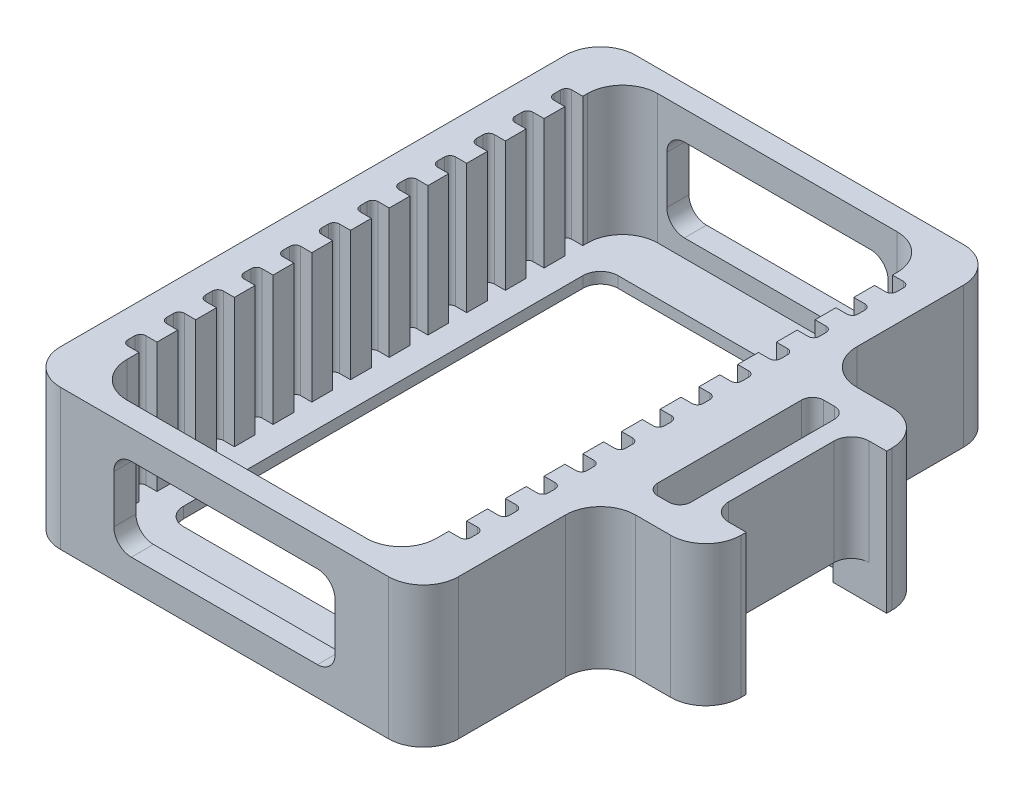
from build123d import *

# Parameters (mm, degrees)
SKETCH2_W                 = 36
SKETCH2_H                 = 52
BOSS_EXTRUDE3_DEPTH       = 12.7
SHELL2_T                  = -1
SHELL2_THICKNESS_2_FACE_W = 34
SHELL2_THICKNESS_2_FACE_H = 11.7
SHELL2_THICKNESS_2_DEPTH  = 1
SHELL2_THICKNESS_3_FACE_W = 34
SHELL2_THICKNESS_3_FACE_H = 11.7
SHELL2_THICKNESS_3_DEPTH  = 1
SHELL2_THICKNESS_4_FACE_W = 48
SHELL2_THICKNESS_4_FACE_H = 11.7
SHELL2_THICKNESS_4_DEPTH  = 3
SHELL2_THICKNESS_5_FACE_W = 48
SHELL2_THICKNESS_5_FACE_H = 11.7
SHELL2_THICKNESS_5_DEPTH  = 3
CUT_EXTRUDE1_DEPTH        = 11.7
LPATTERN1_COUNT           = 12
LPATTERN1_PITCH           = 3.5
LPATTERN1_COPY_1_DEPTH    = 11.7
LPATTERN1_COPY_2_DEPTH    = 11.7
LPATTERN1_COPY_3_DEPTH    = 11.7
LPATTERN1_COPY_4_DEPTH    = 11.7
LPATTERN1_COPY_5_DEPTH    = 11.7
LPATTERN1_COPY_6_DEPTH    = 11.7
LPATTERN1_COPY_7_DEPTH    = 11.7
LPATTERN1_COPY_8_DEPTH    = 11.7
LPATTERN1_COPY_9_DEPTH    = 11.7
LPATTERN1_COPY_10_DEPTH   = 11.7
LPATTERN1_COPY_11_DEPTH   = 11.7
CUT_EXTRUDE3_DEPTH        = 57.473799235
FILLET5_R                 = 3.175
SKETCH9_W                 = 9.525
SKETCH9_H                 = 20
BOSS_EXTRUDE6_DEPTH       = 12.7
CUT_EXTRUDE5_DEPTH        = 40.936394742
SKETCH11_W                = 3.175
SKETCH11_H                = 12.7
CUT_EXTRUDE6_DEPTH        = 40.936394742
FILLET6_R                 = 3.175
CUT_EXTRUDE7_REACH        = 53.291
SKETCH12_W                = 12.7
SKETCH12_H                = 3.175
FILLET8_R                 = 1.5875
SKETCH7_W                 = 23.3
SKETCH7_H                 = 39.3
CUT_EXTRUDE8_DEPTH        = 12.7
FILLET9_R                 = 1.5875


with BuildPart() as part:
    # Sketch2 → Boss-Extrude3 (new body)
    with BuildSketch(Plane(origin=(0, 0, 0), x_dir=(1, 0, 0), z_dir=(0, 1, 0))):
        Rectangle(SKETCH2_W, SKETCH2_H)
    extrude(amount=BOSS_EXTRUDE3_DEPTH)

    # Shell2
    shell2_openings = [part.faces().sort_by_distance(p)[0] for p in [
        (0, 12.7, 0),
    ]]
    offset(amount=SHELL2_T, openings=shell2_openings, kind=Kind.INTERSECTION)

    # Shell2 thickness 2 face (on inner face of the shell) → Shell2 thickness 2 (add)
    with BuildSketch(Plane(origin=(0, 6.85, -25), x_dir=(-1, 0, 0), z_dir=(0, 0, -1))):
        Rectangle(SHELL2_THICKNESS_2_FACE_W, SHELL2_THICKNESS_2_FACE_H)
    extrude(amount=-SHELL2_THICKNESS_2_DEPTH)

    # Shell2 thickness 3 face (on inner face of the shell) → Shell2 thickness 3 (add)
    with BuildSketch(Plane(origin=(0, 6.85, 25), x_dir=(1, 0, 0), z_dir=(0, 0, 1))):
        Rectangle(SHELL2_THICKNESS_3_FACE_W, SHELL2_THICKNESS_3_FACE_H)
    extrude(amount=-SHELL2_THICKNESS_3_DEPTH)

    # Shell2 thickness 4 face (on inner face of the shell) → Shell2 thickness 4 (add)
    with BuildSketch(Plane(origin=(-17, 6.85, 0), x_dir=(0, 0, -1), z_dir=(-1, 0, 0))):
        Rectangle(SHELL2_THICKNESS_4_FACE_W, SHELL2_THICKNESS_4_FACE_H)
    extrude(amount=-SHELL2_THICKNESS_4_DEPTH)

    # Shell2 thickness 5 face (on inner face of the shell) → Shell2 thickness 5 (add)
    with BuildSketch(Plane(origin=(17, 6.85, 0), x_dir=(0, 0, 1), z_dir=(1, 0, 0))):
        Rectangle(SHELL2_THICKNESS_5_FACE_W, SHELL2_THICKNESS_5_FACE_H)
    extrude(amount=-SHELL2_THICKNESS_5_DEPTH)

    # Sketch5 → Cut-Extrude1 (cut)
    with BuildSketch(Plane(origin=(0, 12.7, 0), x_dir=(1, 0, 0), z_dir=(0, 1, 0))):
        with BuildLine():
            Line((-14, 20.4), (-15, 20.4))
            ThreePointArc((-15, 20.4), (-15.353553391, 20.253553391), (-15.5, 19.9))
            Line((-15.5, 19.9), (-15.5, 19.28))
            ThreePointArc((-15.5, 19.28), (-15.353553391, 18.926446609), (-15, 18.78))
            Line((-15, 18.78), (-14, 18.78))
            Line((-14, 18.78), (-14, 20.4))
        make_face()
    cut_extrude1 = extrude(amount=-CUT_EXTRUDE1_DEPTH, mode=Mode.SUBTRACT)

    # Mirror1: Cut-Extrude1 across plane
    add(cut_extrude1.mirror(Plane(origin=(0, 0, 0), x_dir=(0, 0, 1), z_dir=(1, 0, 0))), mode=Mode.SUBTRACT)

    # LPattern1: Cut-Extrude1 ×12
    with Locations(*[(0, 0, i * LPATTERN1_PITCH) for i in range(1, LPATTERN1_COUNT)]):
        add(cut_extrude1, mode=Mode.SUBTRACT)

    # LPattern1 copy 1 sketch → LPattern1 copy 1 (cut)
    with BuildSketch(Plane(origin=(0, 12.7, 3.5), x_dir=(-1, 0, 0), z_dir=(0, 1, 0))):
        with BuildLine():
            Line((-14, -20.4), (-15, -20.4))
            ThreePointArc((-15, -20.4), (-15.353553391, -20.253553391), (-15.5, -19.9))
            Line((-15.5, -19.9), (-15.5, -19.28))
            ThreePointArc((-15.5, -19.28), (-15.353553391, -18.926446609), (-15, -18.78))
            Line((-15, -18.78), (-14, -18.78))
            Line((-14, -18.78), (-14, -20.4))
        make_face()
    extrude(amount=-LPATTERN1_COPY_1_DEPTH, mode=Mode.SUBTRACT)

    # LPattern1 copy 2 sketch → LPattern1 copy 2 (cut)
    with BuildSketch(Plane(origin=(0, 12.7, 7), x_dir=(-1, 0, 0), z_dir=(0, 1, 0))):
        with BuildLine():
            Line((-14, -20.4), (-15, -20.4))
            ThreePointArc((-15, -20.4), (-15.353553391, -20.253553391), (-15.5, -19.9))
            Line((-15.5, -19.9), (-15.5, -19.28))
            ThreePointArc((-15.5, -19.28), (-15.353553391, -18.926446609), (-15, -18.78))
            Line((-15, -18.78), (-14, -18.78))
            Line((-14, -18.78), (-14, -20.4))
        make_face()
    extrude(amount=-LPATTERN1_COPY_2_DEPTH, mode=Mode.SUBTRACT)

    # LPattern1 copy 3 sketch → LPattern1 copy 3 (cut)
    with BuildSketch(Plane(origin=(0, 12.7, 10.5), x_dir=(-1, 0, 0), z_dir=(0, 1, 0))):
        with BuildLine():
            Line((-14, -20.4), (-15, -20.4))
            ThreePointArc((-15, -20.4), (-15.353553391, -20.253553391), (-15.5, -19.9))
            Line((-15.5, -19.9), (-15.5, -19.28))
            ThreePointArc((-15.5, -19.28), (-15.353553391, -18.926446609), (-15, -18.78))
            Line((-15, -18.78), (-14, -18.78))
            Line((-14, -18.78), (-14, -20.4))
        make_face()
    extrude(amount=-LPATTERN1_COPY_3_DEPTH, mode=Mode.SUBTRACT)

    # LPattern1 copy 4 sketch → LPattern1 copy 4 (cut)
    with BuildSketch(Plane(origin=(0, 12.7, 14), x_dir=(-1, 0, 0), z_dir=(0, 1, 0))):
        with BuildLine():
            Line((-14, -20.4), (-15, -20.4))
            ThreePointArc((-15, -20.4), (-15.353553391, -20.253553391), (-15.5, -19.9))
            Line((-15.5, -19.9), (-15.5, -19.28))
            ThreePointArc((-15.5, -19.28), (-15.353553391, -18.926446609), (-15, -18.78))
            Line((-15, -18.78), (-14, -18.78))
            Line((-14, -18.78), (-14, -20.4))
        make_face()
    extrude(amount=-LPATTERN1_COPY_4_DEPTH, mode=Mode.SUBTRACT)

    # LPattern1 copy 5 sketch → LPattern1 copy 5 (cut)
    with BuildSketch(Plane(origin=(0, 12.7, 17.5), x_dir=(-1, 0, 0), z_dir=(0, 1, 0))):
        with BuildLine():
            Line((-14, -20.4), (-15, -20.4))
            ThreePointArc((-15, -20.4), (-15.353553391, -20.253553391), (-15.5, -19.9))
            Line((-15.5, -19.9), (-15.5, -19.28))
            ThreePointArc((-15.5, -19.28), (-15.353553391, -18.926446609), (-15, -18.78))
            Line((-15, -18.78), (-14, -18.78))
            Line((-14, -18.78), (-14, -20.4))
        make_face()
    extrude(amount=-LPATTERN1_COPY_5_DEPTH, mode=Mode.SUBTRACT)

    # LPattern1 copy 6 sketch → LPattern1 copy 6 (cut)
    with BuildSketch(Plane(origin=(0, 12.7, 21), x_dir=(-1, 0, 0), z_dir=(0, 1, 0))):
        with BuildLine():
            Line((-14, -20.4), (-15, -20.4))
            ThreePointArc((-15, -20.4), (-15.353553391, -20.253553391), (-15.5, -19.9))
            Line((-15.5, -19.9), (-15.5, -19.28))
            ThreePointArc((-15.5, -19.28), (-15.353553391, -18.926446609), (-15, -18.78))
            Line((-15, -18.78), (-14, -18.78))
            Line((-14, -18.78), (-14, -20.4))
        make_face()
    extrude(amount=-LPATTERN1_COPY_6_DEPTH, mode=Mode.SUBTRACT)

    # LPattern1 copy 7 sketch → LPattern1 copy 7 (cut)
    with BuildSketch(Plane(origin=(0, 12.7, 24.5), x_dir=(-1, 0, 0), z_dir=(0, 1, 0))):
        with BuildLine():
            Line((-14, -20.4), (-15, -20.4))
            ThreePointArc((-15, -20.4), (-15.353553391, -20.253553391), (-15.5, -19.9))
            Line((-15.5, -19.9), (-15.5, -19.28))
            ThreePointArc((-15.5, -19.28), (-15.353553391, -18.926446609), (-15, -18.78))
            Line((-15, -18.78), (-14, -18.78))
            Line((-14, -18.78), (-14, -20.4))
        make_face()
    extrude(amount=-LPATTERN1_COPY_7_DEPTH, mode=Mode.SUBTRACT)

    # LPattern1 copy 8 sketch → LPattern1 copy 8 (cut)
    with BuildSketch(Plane(origin=(0, 12.7, 28), x_dir=(-1, 0, 0), z_dir=(0, 1, 0))):
        with BuildLine():
            Line((-14, -20.4), (-15, -20.4))
            ThreePointArc((-15, -20.4), (-15.353553391, -20.253553391), (-15.5, -19.9))
            Line((-15.5, -19.9), (-15.5, -19.28))
            ThreePointArc((-15.5, -19.28), (-15.353553391, -18.926446609), (-15, -18.78))
            Line((-15, -18.78), (-14, -18.78))
            Line((-14, -18.78), (-14, -20.4))
        make_face()
    extrude(amount=-LPATTERN1_COPY_8_DEPTH, mode=Mode.SUBTRACT)

    # LPattern1 copy 9 sketch → LPattern1 copy 9 (cut)
    with BuildSketch(Plane(origin=(0, 12.7, 31.5), x_dir=(-1, 0, 0), z_dir=(0, 1, 0))):
        with BuildLine():
            Line((-14, -20.4), (-15, -20.4))
            ThreePointArc((-15, -20.4), (-15.353553391, -20.253553391), (-15.5, -19.9))
            Line((-15.5, -19.9), (-15.5, -19.28))
            ThreePointArc((-15.5, -19.28), (-15.353553391, -18.926446609), (-15, -18.78))
            Line((-15, -18.78), (-14, -18.78))
            Line((-14, -18.78), (-14, -20.4))
        make_face()
    extrude(amount=-LPATTERN1_COPY_9_DEPTH, mode=Mode.SUBTRACT)

    # LPattern1 copy 10 sketch → LPattern1 copy 10 (cut)
    with BuildSketch(Plane(origin=(0, 12.7, 35), x_dir=(-1, 0, 0), z_dir=(0, 1, 0))):
        with BuildLine():
            Line((-14, -20.4), (-15, -20.4))
            ThreePointArc((-15, -20.4), (-15.353553391, -20.253553391), (-15.5, -19.9))
            Line((-15.5, -19.9), (-15.5, -19.28))
            ThreePointArc((-15.5, -19.28), (-15.353553391, -18.926446609), (-15, -18.78))
            Line((-15, -18.78), (-14, -18.78))
            Line((-14, -18.78), (-14, -20.4))
        make_face()
    extrude(amount=-LPATTERN1_COPY_10_DEPTH, mode=Mode.SUBTRACT)

    # LPattern1 copy 11 sketch → LPattern1 copy 11 (cut)
    with BuildSketch(Plane(origin=(0, 12.7, 38.5), x_dir=(-1, 0, 0), z_dir=(0, 1, 0))):
        with BuildLine():
            Line((-14, -20.4), (-15, -20.4))
            ThreePointArc((-15, -20.4), (-15.353553391, -20.253553391), (-15.5, -19.9))
            Line((-15.5, -19.9), (-15.5, -19.28))
            ThreePointArc((-15.5, -19.28), (-15.353553391, -18.926446609), (-15, -18.78))
            Line((-15, -18.78), (-14, -18.78))
            Line((-14, -18.78), (-14, -20.4))
        make_face()
    extrude(amount=-LPATTERN1_COPY_11_DEPTH, mode=Mode.SUBTRACT)

    # Sketch8 → Cut-Extrude3 (cut, through all)
    with BuildSketch(Plane(origin=(0, 0, -26), x_dir=(-1, 0, 0), z_dir=(0, 0, -1))):
        with BuildLine():
            Line((-8.4125, 10.1), (8.4125, 10.1))
            ThreePointArc((8.4125, 10.1), (9.535032015, 9.635032015), (10, 8.5125))
            Line((10, 8.5125), (10, 4.1875))
            ThreePointArc((10, 4.1875), (9.535032015, 3.064967985), (8.4125, 2.6))
            Line((8.4125, 2.6), (-8.4125, 2.6))
            ThreePointArc((-8.4125, 2.6), (-9.535032015, 3.064967985), (-10, 4.1875))
            Line((-10, 4.1875), (-10, 8.5125))
            ThreePointArc((-10, 8.5125), (-9.535032015, 9.635032015), (-8.4125, 10.1))
        make_face()
    extrude(amount=-CUT_EXTRUDE3_DEPTH, mode=Mode.SUBTRACT)

    # Fillet5
    fillet5_edges = [part.edges().sort_by_distance(p)[0] for p in [
        (14, 6.85, -24),
        (-14, 6.85, -24),
        (-14, 6.85, 24),
        (14, 6.85, 24),
        (-18, 6.35, -26),
        (-18, 6.35, 26),
        (18, 6.35, 26),
        (18, 6.35, -26),
    ]]
    fillet(fillet5_edges, radius=FILLET5_R)

    # Sketch9 → Boss-Extrude6 (add)
    with BuildSketch(Plane(origin=(0, 12.7, 0), x_dir=(1, 0, 0), z_dir=(0, 1, 0))):
        with Locations((22.7625, 0)):
            Rectangle(SKETCH9_W, SKETCH9_H)
    extrude(amount=-BOSS_EXTRUDE6_DEPTH)

    # Sketch10 → Cut-Extrude5 (cut, through all)
    with BuildSketch(Plane(origin=(0, 0, 0), x_dir=(1, 0, 0), z_dir=(0, 1, 0))):
        with BuildLine():
            Line((20.675, 7.5), (21.675, 7.5))
            ThreePointArc((21.675, 7.5), (22.382106781, 7.207106781), (22.675, 6.5))
            Line((22.675, 6.5), (22.675, -6.5))
            ThreePointArc((22.675, -6.5), (22.382106781, -7.207106781), (21.675, -7.5))
            Line((21.675, -7.5), (20.675, -7.5))
            ThreePointArc((20.675, -7.5), (19.967893219, -7.207106781), (19.675, -6.5))
            Line((19.675, -6.5), (19.675, 6.5))
            ThreePointArc((19.675, 6.5), (19.967893219, 7.207106781), (20.675, 7.5))
        make_face()
    extrude(amount=CUT_EXTRUDE5_DEPTH, mode=Mode.SUBTRACT)

    # Sketch11 → Cut-Extrude6 (cut, through all)
    with BuildSketch(Plane(origin=(0, 12.7, 0), x_dir=(1, 0, 0), z_dir=(0, 1, 0))):
        with Locations((25.9375, 0)):
            Rectangle(SKETCH11_W, SKETCH11_H)
    extrude(amount=-CUT_EXTRUDE6_DEPTH, mode=Mode.SUBTRACT)

    # Fillet6
    fillet6_edges = [part.edges().sort_by_distance(p)[0] for p in [
        (27.525, 6.35, 10),
        (27.525, 6.35, -10),
        (18, 6.35, -10),
        (18, 6.35, 10),
    ]]
    fillet(fillet6_edges, radius=FILLET6_R)

    # Sketch12 → Cut-Extrude7 (cut, up to next)
    with BuildSketch(Plane(origin=(24.35, 0, 0), x_dir=(0, 0, -1), z_dir=(1, 0, 0)), mode=Mode.PRIVATE) as cut_extrude7_sk1:
        with Locations((0, 1.5875)):
            Rectangle(SKETCH12_W, SKETCH12_H)
    cut_extrude7_tool1 = extrude(cut_extrude7_sk1.sketch, amount=-CUT_EXTRUDE7_REACH, mode=Mode.PRIVATE) & part.part
    add(cut_extrude7_tool1.solids().sort_by_distance((24.35, 1.5875, 0))[0], mode=Mode.SUBTRACT)

    # Fillet8
    fillet8_edges = [part.edges().sort_by_distance(p)[0] for p in [
        (24.35, 7.9375, -6.35),
        (24.35, 7.9375, 6.35),
    ]]
    fillet(fillet8_edges, radius=FILLET8_R)

    # Sketch7 → Cut-Extrude8 (cut)
    with BuildSketch(Plane.XZ):
        Rectangle(SKETCH7_W, SKETCH7_H)
    extrude(amount=-CUT_EXTRUDE8_DEPTH, mode=Mode.SUBTRACT)

    # Fillet9
    fillet9_edges = [part.edges().sort_by_distance(p)[0] for p in [
        (-11.65, 0.5, -19.65),
        (-11.65, 0.5, 19.65),
        (11.65, 0.5, 19.65),
        (11.65, 0.5, -19.65),
    ]]
    fillet(fillet9_edges, radius=FILLET9_R)


solid = part.part
